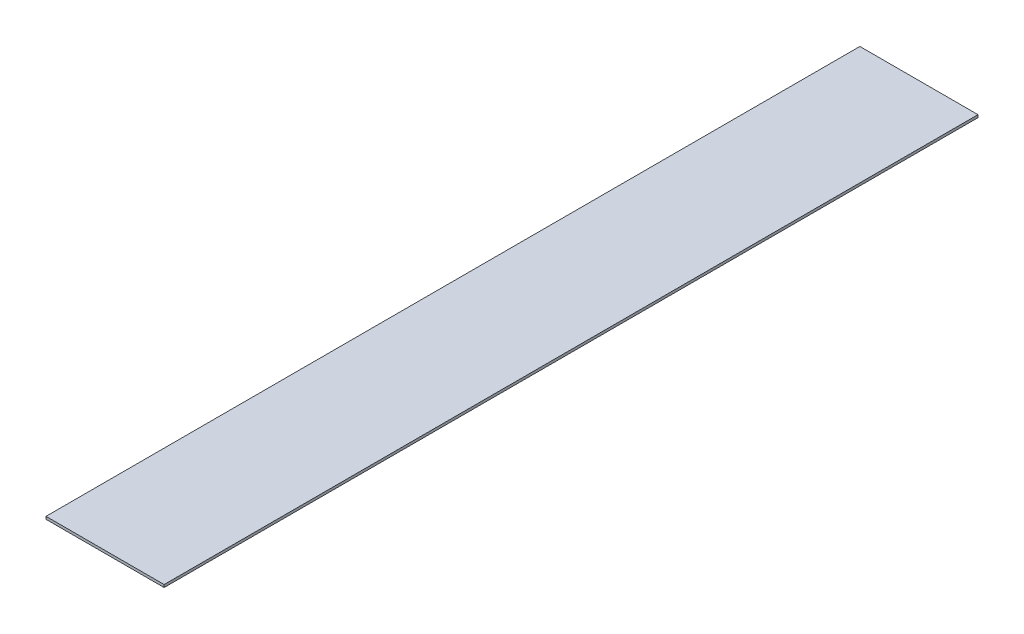
from build123d import *

# Parameters (mm, degrees)
SKETCH1_W           = 90
SKETCH1_H           = 620
BOSS_EXTRUDE1_DEPTH = 2


with BuildPart() as part:
    # Sketch1 → Boss-Extrude1 (new body)
    with BuildSketch(Plane(origin=(0, 0, 0), x_dir=(1, 0, 0), z_dir=(0, 1, 0))):
        Rectangle(SKETCH1_W, SKETCH1_H)
    extrude(amount=BOSS_EXTRUDE1_DEPTH)


solid = part.part
